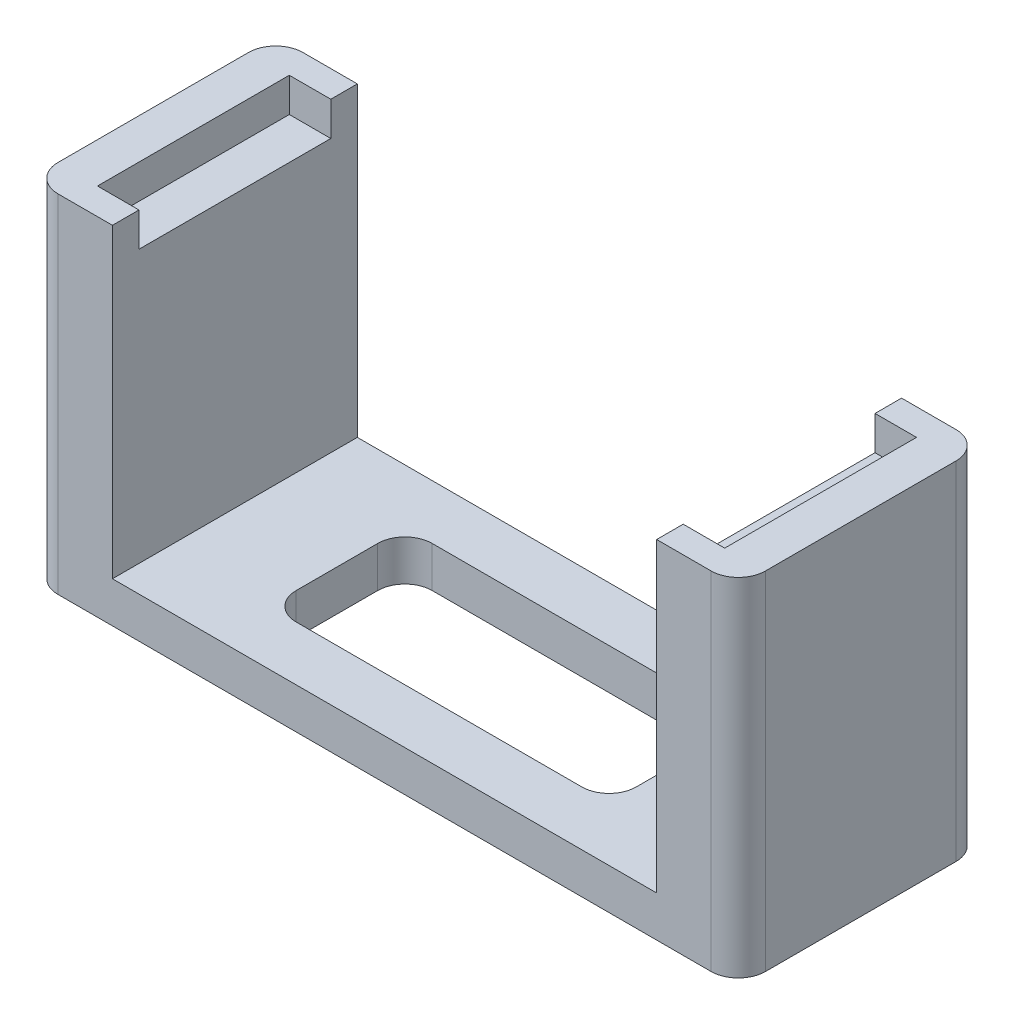
from build123d import *

# Parameters (mm, degrees)
SKETCH1_W           = 52
SKETCH1_H           = 18
BOSS_EXTRUDE1_DEPTH = 25.5
SKETCH2_W           = 46.1
SKETCH2_H           = 14.1
CUT_EXTRUDE1_DEPTH  = 2.5
SKETCH4_W           = 40
SKETCH4_H           = 18
CUT_EXTRUDE2_DEPTH  = 22.5
SKETCH5_W           = 25
SKETCH5_H           = 10
CUT_EXTRUDE3_DEPTH  = 4
FILLET1_R           = 2
FILLET2_R           = 2


with BuildPart() as part:
    # Sketch1 → Boss-Extrude1 (new body)
    with BuildSketch(Plane(origin=(0, 0, 0), x_dir=(1, 0, 0), z_dir=(0, 1, 0))):
        Rectangle(SKETCH1_W, SKETCH1_H)
    extrude(amount=BOSS_EXTRUDE1_DEPTH)

    # Sketch2 → Cut-Extrude1 (cut)
    with BuildSketch(Plane(origin=(0, 25.5, 0), x_dir=(1, 0, 0), z_dir=(0, 1, 0))):
        Rectangle(SKETCH2_W, SKETCH2_H)
    extrude(amount=-CUT_EXTRUDE1_DEPTH, mode=Mode.SUBTRACT)

    # Sketch4 → Cut-Extrude2 (cut)
    with BuildSketch(Plane(origin=(0, 25.5, 0), x_dir=(1, 0, 0), z_dir=(0, 1, 0))):
        Rectangle(SKETCH4_W, SKETCH4_H)
    extrude(amount=-CUT_EXTRUDE2_DEPTH, mode=Mode.SUBTRACT)

    # Sketch5 → Cut-Extrude3 (cut, through all)
    with BuildSketch(Plane(origin=(0, 3, 0), x_dir=(1, 0, 0), z_dir=(0, 1, 0))):
        Rectangle(SKETCH5_W, SKETCH5_H)
    extrude(amount=-CUT_EXTRUDE3_DEPTH, mode=Mode.SUBTRACT)

    # Fillet1
    fillet1_edges = [part.edges().sort_by_distance(p)[0] for p in [
        (-26, 12.75, -9),
        (26, 12.75, -9),
        (26, 12.75, 9),
        (-26, 12.75, 9),
    ]]
    fillet(fillet1_edges, radius=FILLET1_R)

    # Fillet2
    fillet2_edges = [part.edges().sort_by_distance(p)[0] for p in [
        (-12.5, 1.5, 5),
        (-12.5, 1.5, -5),
        (12.5, 1.5, -5),
        (12.5, 1.5, 5),
    ]]
    fillet(fillet2_edges, radius=FILLET2_R)


solid = part.part
